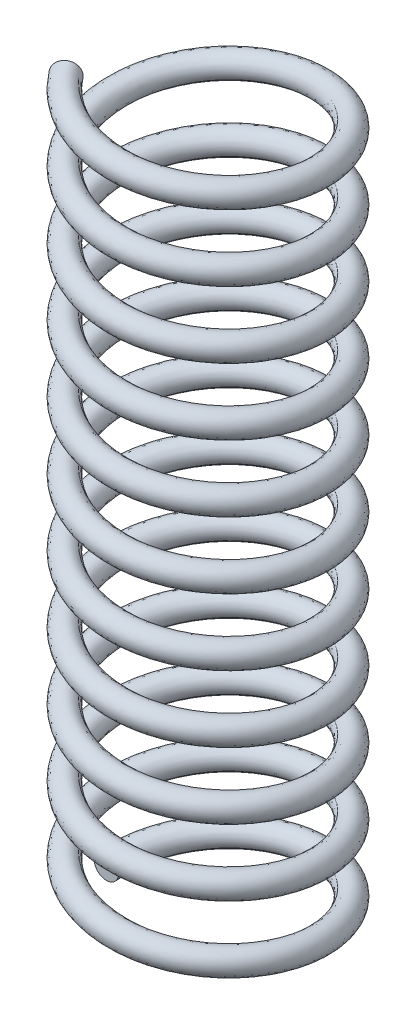
from build123d import *

# Parameters (mm, degrees)
SWEEP1_PITCH       = 7.235504587
SWEEP1_HEIGHT      = 78.867
SWEEP1_RADIUS      = 12.3825
SWEEP1_START_ANGLE = -90
SKETCH2_R          = 1.3335


with BuildPart() as part:
    # Sweep1: sweep along a helix
    with BuildLine() as sweep1_path:
        add(Helix(SWEEP1_PITCH, SWEEP1_HEIGHT, SWEEP1_RADIUS, center=(0, 0, 0), direction=(0, 1, 0), lefthand=True, mode=Mode.PRIVATE).rotate(Axis((0, 0, 0), (0, 1, 0)), SWEEP1_START_ANGLE))
    # Sketch2 → Sweep1 (sweep)
    with BuildSketch(Plane.XY):
        with Locations((-11.049, 1.3335)):
            Circle(SKETCH2_R)
    sweep(path=sweep1_path.line, is_frenet=True)


solid = part.part
